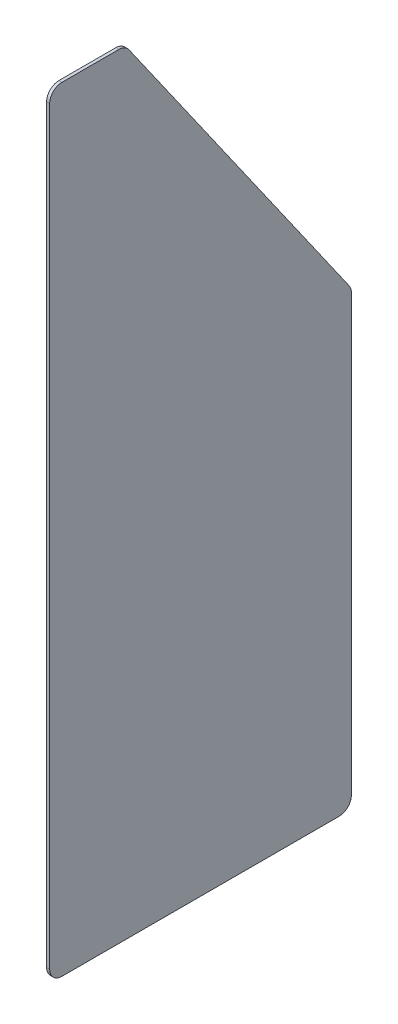
from build123d import *

# Parameters (mm, degrees)
SKETCH1_W           = 1.5875
SKETCH1_H           = 155.8925
BOSS_EXTRUDE1_DEPTH = 400.05
CUT_EXTRUDE1_DEPTH  = 1.5875
FILLET1_R           = 6.35


with BuildPart() as part:
    # Sketch1 → Boss-Extrude1 (new body)
    with BuildSketch(Plane(origin=(0, 0, 0), x_dir=(1, 0, 0), z_dir=(0, 1, 0))):
        with Locations((0.79375, 77.94625)):
            Rectangle(SKETCH1_W, SKETCH1_H)
    extrude(amount=BOSS_EXTRUDE1_DEPTH)

    # Sketch2 → Cut-Extrude1 (cut)
    with BuildSketch(Plane.ZY):
        Polygon((-39.043266439, 400.05), (-155.8925, 233.172), (-155.8925, 400.05), align=None)
    extrude(amount=-CUT_EXTRUDE1_DEPTH, mode=Mode.SUBTRACT)

    # Fillet1
    fillet1_edges = [part.edges().sort_by_distance(p)[0] for p in [
        (0.79375, 400.05, -39.043266439),
        (0.79375, 233.172, -155.8925),
        (0.79375, 400.05, 0),
        (0.79375, 0, -155.8925),
        (0.79375, 0, 0),
    ]]
    fillet(fillet1_edges, radius=FILLET1_R)


solid = part.part
